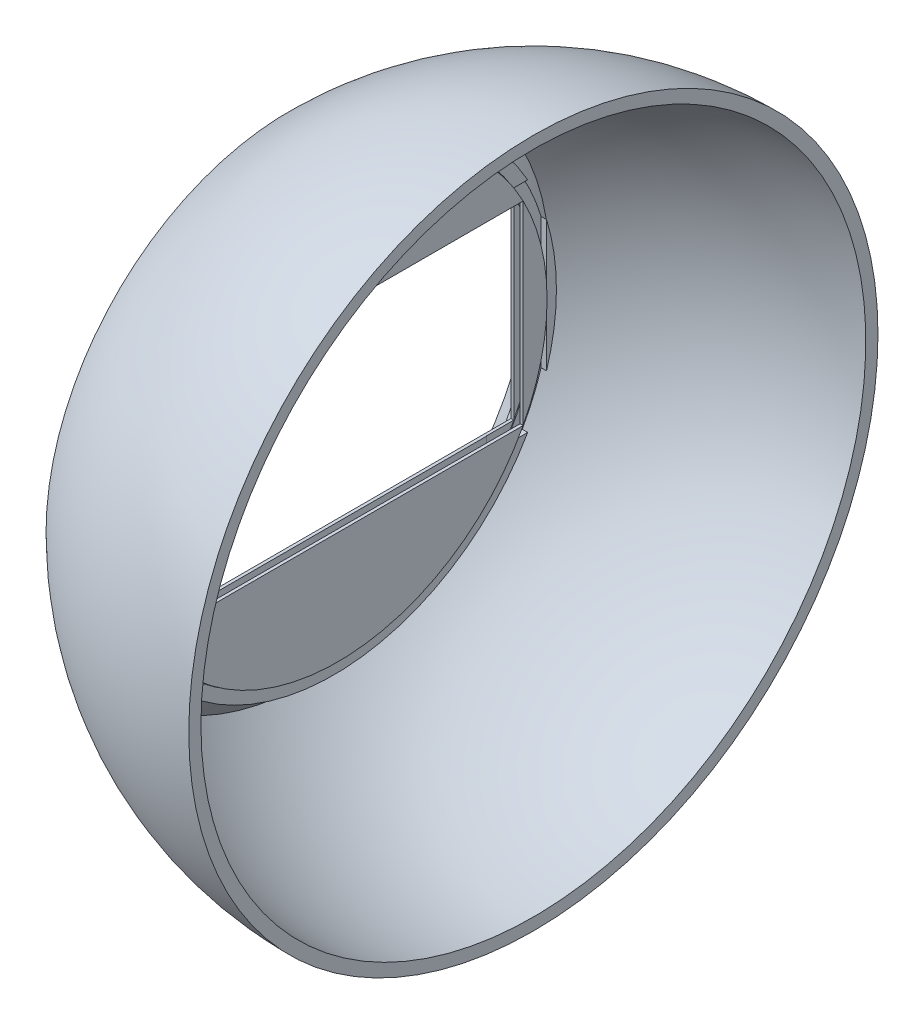
from build123d import *

# Parameters (mm, degrees)
BOSS_EXTRUDE1_DEPTH   = 2
BOSS_EXTRUDE1_2_DEPTH = 2
BOSS_EXTRUDE1_3_DEPTH = 2
BOSS_EXTRUDE1_4_DEPTH = 2
SKETCH9_W             = 1
SKETCH9_H             = 61
CUT_EXTRUDE1_DEPTH    = 2
SKETCH10_W            = 1
SKETCH10_H            = 61
CUT_EXTRUDE2_DEPTH    = 2
SKETCH12_W            = 1
SKETCH12_H            = 36
CUT_EXTRUDE3_DEPTH    = 2
SKETCH13_W            = 1
SKETCH13_H            = 36
CUT_EXTRUDE8_DEPTH    = 4.5


with BuildPart() as part:
    # Sketch1 → Revolve1 (revolve)
    with BuildSketch(Plane.XY):
        with BuildLine():
            Line((-40.206859547, 40), (-34.828674339, 34.621814792))
            Line((-34.828674339, 34.621814792), (-32.828674339, 34.621814792))
            Line((-32.828674339, 34.621814792), (-32.828674339, 36.621814792))
            Line((-32.828674339, 36.621814792), (-34.000247215, 36.621814792))
            Line((-34.000247215, 36.621814792), (-37.356354939, 39.977922516))
            ThreePointArc((-37.356354939, 39.977922516), (-20.079086089, 50.897562268), (0, 54.715002906))
            Line((0, 54.715002906), (0, 56.715002906))
            ThreePointArc((0, 56.715002906), (-21.771442745, 52.369798887), (-40.206859547, 40))
        make_face()
    revolve(axis=Axis((-112.648728237, 0, 0), (1, 0, 0)))


with BuildPart() as body_2:
    # Sketch7 → Boss-Extrude1 (new body)
    with BuildSketch(Plane(origin=(-34.185, 0, 0), x_dir=(0, 0, -1), z_dir=(1, 0, 0))):
        with BuildLine():
            ThreePointArc((30.5, 16), (0, 34.441980199), (-30.5, 16))
            Line((-30.5, 16), (30.5, 16))
        make_face()
    extrude(amount=BOSS_EXTRUDE1_DEPTH)


with BuildPart() as body_3:
    # Sketch7 → Boss-Extrude1 2 (new body)
    with BuildSketch(Plane(origin=(-34.185, 0, 0), x_dir=(0, 0, -1), z_dir=(1, 0, 0))):
        with BuildLine():
            Line((-30.5, -16), (-30.5, 16))
            ThreePointArc((-30.5, 16), (-34.441980199, 0), (-30.5, -16))
        make_face()
    extrude(amount=BOSS_EXTRUDE1_2_DEPTH)


with BuildPart() as body_4:
    # Sketch7 → Boss-Extrude1 3 (new body)
    with BuildSketch(Plane(origin=(-34.185, 0, 0), x_dir=(0, 0, -1), z_dir=(1, 0, 0))):
        with BuildLine():
            Line((30.5, -16), (-30.5, -16))
            ThreePointArc((-30.5, -16), (0, -34.441980199), (30.5, -16))
        make_face()
    extrude(amount=BOSS_EXTRUDE1_3_DEPTH)


with BuildPart() as body_5:
    # Sketch7 → Boss-Extrude1 4 (new body)
    with BuildSketch(Plane(origin=(-34.185, 0, 0), x_dir=(0, 0, -1), z_dir=(1, 0, 0))):
        with BuildLine():
            ThreePointArc((34.441980199, 0), (33.441967616, 8.239223384), (30.5, 16))
            Line((30.5, 16), (30.5, -16))
            ThreePointArc((30.5, -16), (33.441967616, -8.239223384), (34.441980199, 0))
        make_face()
    extrude(amount=BOSS_EXTRUDE1_4_DEPTH)


with BuildPart() as cut_extrude1_tool:
    # Sketch9 → Cut-Extrude1 (new body)
    with BuildSketch(Plane.XZ.offset(-16)):
        with Locations((-33.185, 0)):
            Rectangle(SKETCH9_W, SKETCH9_H)
    extrude(amount=-CUT_EXTRUDE1_DEPTH)


with BuildPart() as part_1:
    add(part.part)

    # Cut-Extrude1: cut by cut_extrude1_tool
    add(cut_extrude1_tool.part, mode=Mode.SUBTRACT)


with BuildPart() as body_2_1:
    add(body_2.part)

    # Cut-Extrude1: cut by cut_extrude1_tool
    add(cut_extrude1_tool.part, mode=Mode.SUBTRACT)


with BuildPart() as cut_extrude2_tool:
    # Sketch10 → Cut-Extrude2 (new body)
    with BuildSketch(Plane(origin=(0, -16, 0), x_dir=(1, 0, 0), z_dir=(0, 1, 0))):
        with Locations((-33.185, 0)):
            Rectangle(SKETCH10_W, SKETCH10_H)
    extrude(amount=-CUT_EXTRUDE2_DEPTH)


with BuildPart() as part_2:
    add(part_1.part)

    # Cut-Extrude2: cut by cut_extrude2_tool
    add(cut_extrude2_tool.part, mode=Mode.SUBTRACT)


with BuildPart() as body_4_1:
    add(body_4.part)

    # Cut-Extrude2: cut by cut_extrude2_tool
    add(cut_extrude2_tool.part, mode=Mode.SUBTRACT)


with BuildPart() as cut_extrude3_tool:
    # Sketch12 → Cut-Extrude3 (new body)
    with BuildSketch(Plane(origin=(0, 0, 30.5), x_dir=(-1, 0, 0), z_dir=(0, 0, -1))):
        with Locations((33.185, 0)):
            Rectangle(SKETCH12_W, SKETCH12_H)
    extrude(amount=-CUT_EXTRUDE3_DEPTH)


with BuildPart() as part_3:
    add(part_2.part)

    # Cut-Extrude3: cut by cut_extrude3_tool
    add(cut_extrude3_tool.part, mode=Mode.SUBTRACT)


with BuildPart() as body_3_1:
    add(body_3.part)

    # Cut-Extrude3: cut by cut_extrude3_tool
    add(cut_extrude3_tool.part, mode=Mode.SUBTRACT)


with BuildPart() as cut_extrude8_tool:
    # Sketch13 → Cut-Extrude8 (new body, symmetric)
    with BuildSketch(Plane.XY.offset(-30.5)):
        with Locations((-33.225443476, 0)):
            Rectangle(SKETCH13_W, SKETCH13_H)
    extrude(amount=CUT_EXTRUDE8_DEPTH, both=True)


with BuildPart() as part_4:
    add(part_3.part)

    # Cut-Extrude8: cut by cut_extrude8_tool
    add(cut_extrude8_tool.part, mode=Mode.SUBTRACT)


with BuildPart() as body_2_2:
    add(body_2_1.part)

    # Cut-Extrude8: cut by cut_extrude8_tool
    add(cut_extrude8_tool.part, mode=Mode.SUBTRACT)


with BuildPart() as body_4_2:
    add(body_4_1.part)

    # Cut-Extrude8: cut by cut_extrude8_tool
    add(cut_extrude8_tool.part, mode=Mode.SUBTRACT)


with BuildPart() as body_5_1:
    add(body_5.part)

    # Cut-Extrude8: cut by cut_extrude8_tool
    add(cut_extrude8_tool.part, mode=Mode.SUBTRACT)


solid = Compound([body_3_1.part, part_4.part, body_2_2.part, body_4_2.part, body_5_1.part])
